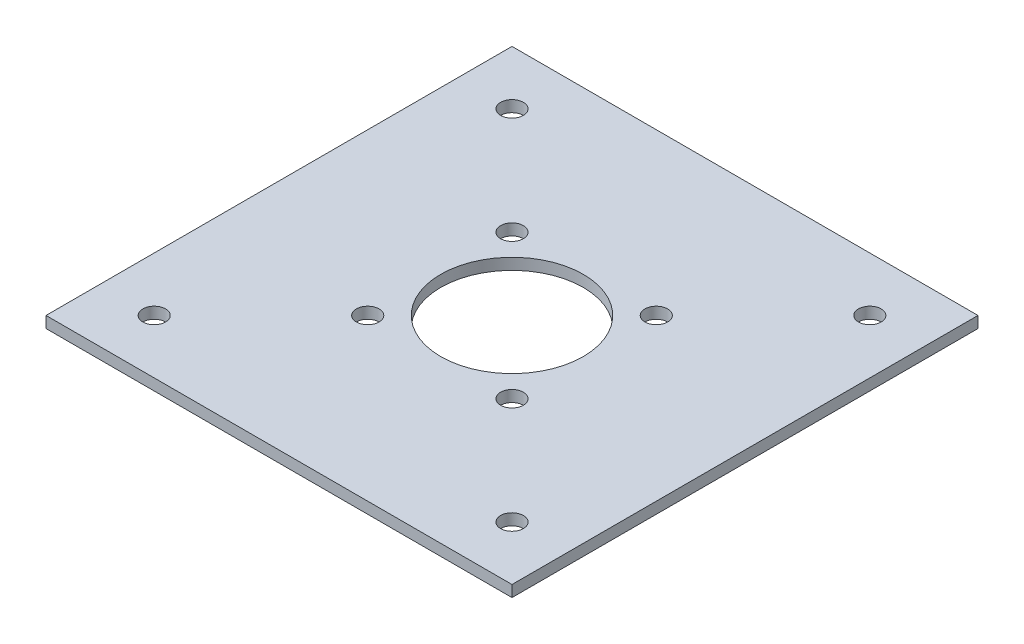
from build123d import *

# Parameters (mm, degrees)
SKETCH1_W           = 82.042
SKETCH1_H           = 82.042
BOSS_EXTRUDE1_DEPTH = 2
SKETCH2_R           = 2
CUT_EXTRUDE1_DEPTH  = 3
SKETCH3_R           = 12.5476
CUT_EXTRUDE2_DEPTH  = 3


with BuildPart() as part:
    # Sketch1 → Boss-Extrude1 (new body)
    with BuildSketch(Plane(origin=(0, 0, 0), x_dir=(1, 0, 0), z_dir=(0, 1, 0))):
        with Locations((41.021, 41.021)):
            Rectangle(SKETCH1_W, SKETCH1_H)
    extrude(amount=BOSS_EXTRUDE1_DEPTH)

    # Sketch2 → Cut-Extrude1 (cut, through all)
    with BuildSketch(Plane(origin=(0, 2, 0), x_dir=(-1, 0, 0), z_dir=(0, 1, 0))):
        with Locations((-28.321, -53.721)):
            Circle(SKETCH2_R)
        with Locations((-53.721, -53.721)):
            Circle(SKETCH2_R)
        with Locations((-53.721, -28.321)):
            Circle(SKETCH2_R)
        with Locations((-28.321, -28.321)):
            Circle(SKETCH2_R)
        with Locations((-9.525, -9.525)):
            Circle(SKETCH2_R)
        with Locations((-9.525, -72.517)):
            Circle(SKETCH2_R)
        with Locations((-72.517, -9.525)):
            Circle(SKETCH2_R)
        with Locations((-72.517, -72.517)):
            Circle(SKETCH2_R)
    extrude(amount=-CUT_EXTRUDE1_DEPTH, mode=Mode.SUBTRACT)

    # Sketch3 → Cut-Extrude2 (cut, through all)
    with BuildSketch(Plane(origin=(0, 2, 0), x_dir=(1, 0, 0), z_dir=(0, 1, 0))):
        with Locations((41.021, 41.021)):
            Circle(SKETCH3_R)
    extrude(amount=-CUT_EXTRUDE2_DEPTH, mode=Mode.SUBTRACT)


solid = part.part
